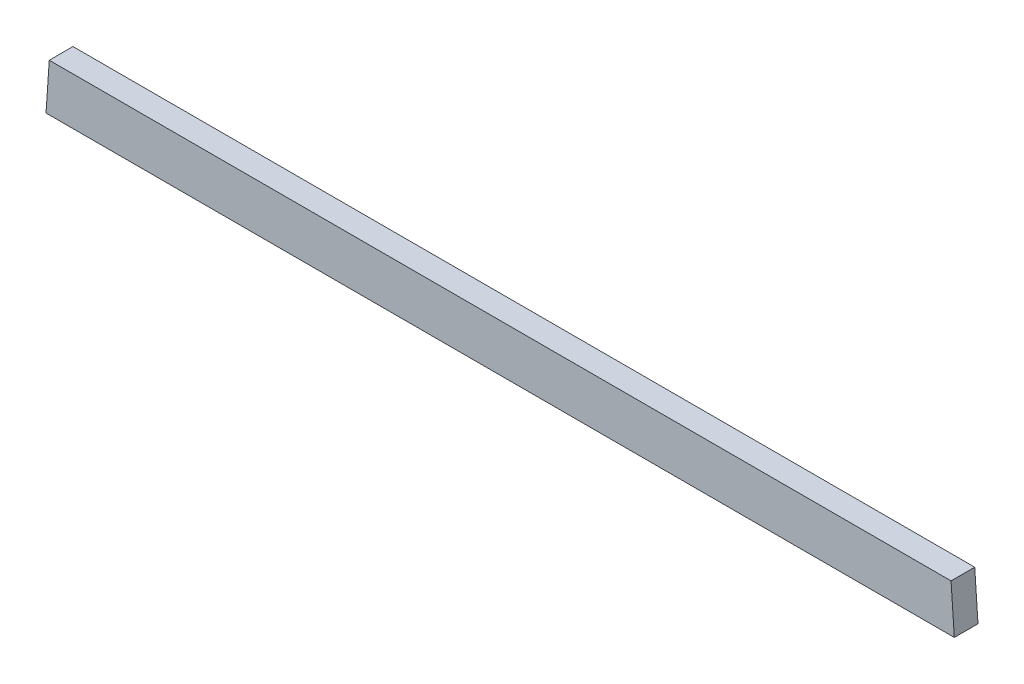
from build123d import *

# Parameters (mm, degrees)
BOSS_EXTRUDE1_DEPTH = 19.05


with BuildPart() as part:
    # Sketch1 → Boss-Extrude1 (new body)
    with BuildSketch(Plane.XY):
        Polygon((-365.234482759, -19.05), (365.234482759, -19.05), (362.606896552, 19.05), (-362.606896552, 19.05), align=None)
    extrude(amount=BOSS_EXTRUDE1_DEPTH)


solid = part.part
